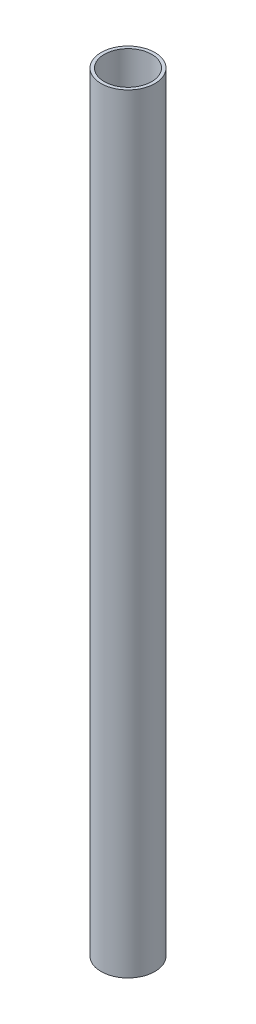
from build123d import *

# Parameters (mm, degrees)
SKETCH1_R           = 10.5
SKETCH1_R_2         = 9.25
BOSS_EXTRUDE1_DEPTH = 300


with BuildPart() as part:
    # Sketch1 → Boss-Extrude1 (new body)
    with BuildSketch(Plane(origin=(0, 0, 0), x_dir=(1, 0, 0), z_dir=(0, 1, 0))):
        Circle(SKETCH1_R)
        Circle(SKETCH1_R_2, mode=Mode.SUBTRACT)
    extrude(amount=BOSS_EXTRUDE1_DEPTH)


solid = part.part
